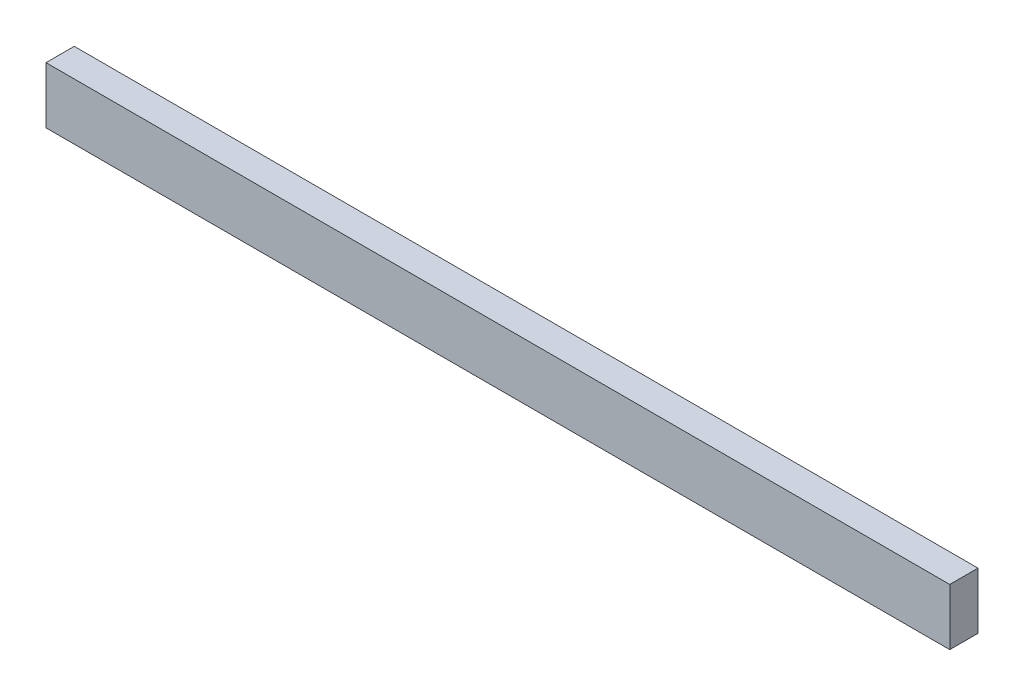
from build123d import *

# Parameters (mm, degrees)
SKETCH1_W           = 101.6
SKETCH1_H           = 6.35
BOSS_EXTRUDE1_DEPTH = 3.175


with BuildPart() as part:
    # Sketch1 → Boss-Extrude1 (new body)
    with BuildSketch(Plane.XY):
        with Locations((7.712449405, 11.475217362)):
            Rectangle(SKETCH1_W, SKETCH1_H)
    extrude(amount=BOSS_EXTRUDE1_DEPTH)


solid = part.part
